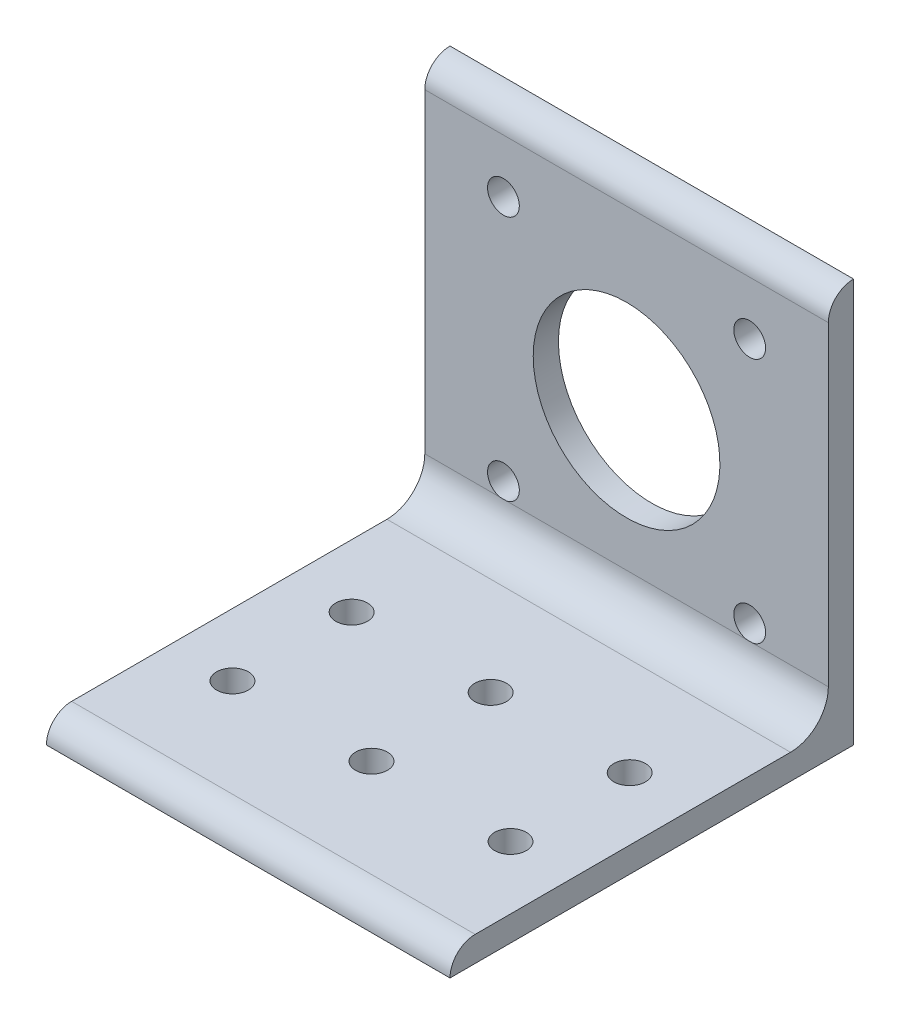
from build123d import *

# Parameters (mm, degrees)
HIERRO_ANGULAR_2_X_2_X_0_125_1_DEPTH = 50.8
CROQUIS3_R                           = 11.75
CROQUIS3_R_2                         = 2
CORTAR_EXTRUIR1_DEPTH                = 3.175
CROQUIS4_R                           = 2
CORTAR_EXTRUIR2_DEPTH                = 3.175


with BuildPart() as part:
    # Sketch1 → Hierro angular 2 X 2 X 0.125(1) (new body)
    with BuildSketch(Plane.YZ.offset(-25.4)):
        with BuildLine():
            Line((0, 0), (0, 50.8))
            Line((0, 50.8), (0.00508, 50.8))
            ThreePointArc((0.00508, 50.8), (2.246551928, 49.871551928), (3.175, 47.63008))
            Line((3.175, 47.63008), (3.175, 7.9375))
            ThreePointArc((3.175, 7.9375), (4.569903955, 4.569903955), (7.9375, 3.175))
            Line((7.9375, 3.175), (47.63008, 3.175))
            ThreePointArc((47.63008, 3.175), (49.871551928, 2.246551928), (50.8, 0.00508))
            Line((50.8, 0.00508), (50.8, 0))
            Line((50.8, 0), (0, 0))
        make_face()
    extrude(amount=HIERRO_ANGULAR_2_X_2_X_0_125_1_DEPTH)

    # Croquis3 → Cortar-Extruir1 (cut)
    with BuildSketch(Plane(origin=(0, 0, 0), x_dir=(-1, 0, 0), z_dir=(0, 0, -1))):
        with Locations((0, 25.4)):
            Circle(CROQUIS3_R)
        with Locations((-15.5, 40.9)):
            Circle(CROQUIS3_R_2)
        with Locations((15.5, 40.9)):
            Circle(CROQUIS3_R_2)
        with Locations((15.5, 9.9)):
            Circle(CROQUIS3_R_2)
        with Locations((-15.5, 9.9)):
            Circle(CROQUIS3_R_2)
    extrude(amount=-CORTAR_EXTRUIR1_DEPTH, mode=Mode.SUBTRACT)

    # Croquis4 → Cortar-Extruir2 (cut)
    with BuildSketch(Plane(origin=(0, 3.175, 0), x_dir=(1, 0, 0), z_dir=(0, 1, 0))):
        with Locations(Location((-17.5, -20.28379, 0), (0, 0, 270))):
            Circle(CROQUIS4_R)
        with Locations(Location((17.5, -20.28379, 0), (0, 0, 270))):
            Circle(CROQUIS4_R)
        with Locations(Location((17.5, -35.28379, 0), (0, 0, 270))):
            Circle(CROQUIS4_R)
        with Locations(Location((-17.5, -35.28379, 0), (0, 0, 270))):
            Circle(CROQUIS4_R)
        with Locations(Location((0, -20.28379, 0), (0, 0, 270))):
            Circle(CROQUIS4_R)
        with Locations(Location((0, -35.28379, 0), (0, 0, 270))):
            Circle(CROQUIS4_R)
    extrude(amount=-CORTAR_EXTRUIR2_DEPTH, mode=Mode.SUBTRACT)


solid = part.part
